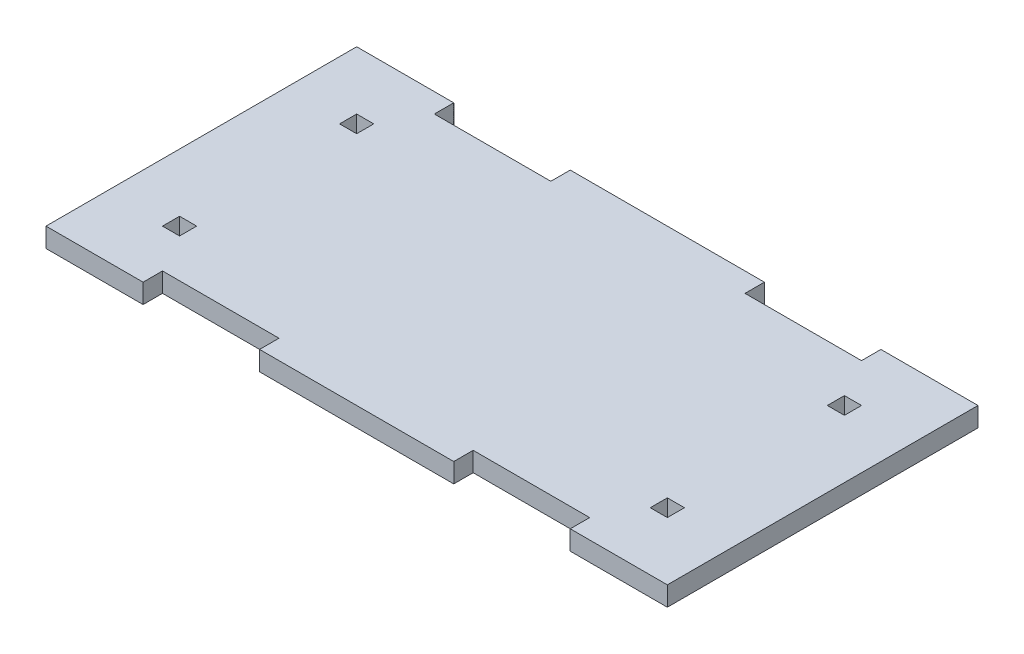
from build123d import *

# Parameters (mm, degrees)
SKETCH1_W           = 5.588
SKETCH1_H           = 5.588
BOSS_EXTRUDE1_DEPTH = 6.35


with BuildPart() as part:
    # Sketch1 → Boss-Extrude1 (new body)
    with BuildSketch(Plane(origin=(0, 0, 0), x_dir=(1, 0, 0), z_dir=(0, 1, 0))):
        Polygon((-101.6, 50.8), (-101.6, -50.8), (-69.85, -50.8), (-69.85, -44.45), (-31.75, -44.45), (-31.75, -50.8), (31.75, -50.8), (31.75, -44.45), (69.85, -44.45), (69.85, -50.8), (101.6, -50.8), (101.6, 50.8), (69.85, 50.8), (69.85, 44.45), (31.75, 44.45), (31.75, 50.8), (-31.75, 50.8), (-31.75, 44.45), (-69.85, 44.45), (-69.85, 50.8), align=None)
        with Locations((-79.756, -28.956)):
            Rectangle(SKETCH1_W, SKETCH1_H, mode=Mode.SUBTRACT)
        with Locations((79.756, -28.956)):
            Rectangle(SKETCH1_W, SKETCH1_H, mode=Mode.SUBTRACT)
        with Locations((-79.756, 28.956)):
            Rectangle(SKETCH1_W, SKETCH1_H, mode=Mode.SUBTRACT)
        with Locations((79.756, 28.956)):
            Rectangle(SKETCH1_W, SKETCH1_H, mode=Mode.SUBTRACT)
    extrude(amount=BOSS_EXTRUDE1_DEPTH)


solid = part.part
